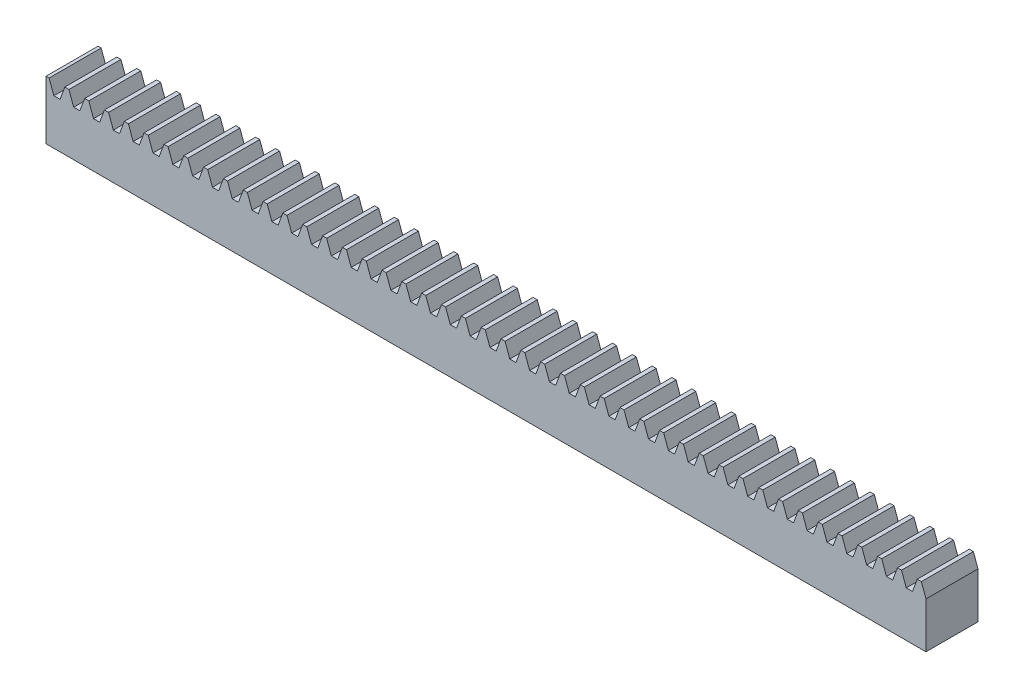
from build123d import *

# Parameters (mm, degrees)
SKETCH1_W           = 67.650000082
SKETCH1_H           = 4
BOSS_EXTRUDE1_DEPTH = 4.5
CUT_EXTRUDE1_DEPTH  = 5


with BuildPart() as part:
    # Sketch1 → Boss-Extrude1 (new body)
    with BuildSketch(Plane(origin=(0, 0, 0), x_dir=(1, 0, 0), z_dir=(0, 1, 0))):
        with Locations((33.825000041, 2)):
            Rectangle(SKETCH1_W, SKETCH1_H)
    extrude(amount=BOSS_EXTRUDE1_DEPTH)

    # Sketch2 → Cut-Extrude1 (cut, through all)
    with BuildSketch(Plane.XY):
        Polygon((0.239013956, 4.5), (0.60298419, 3.5), (0.841998146, 3.5), (1.081012101, 3.5), (1.444982335, 4.5), align=None)
        Polygon((1.763013956, 4.5), (2.12698419, 3.5), (2.365998146, 3.5), (2.605012101, 3.5), (2.968982335, 4.5), align=None)
        Polygon((3.287013956, 4.5), (3.65098419, 3.5), (3.889998146, 3.5), (4.129012101, 3.5), (4.492982335, 4.5), align=None)
        Polygon((4.811013956, 4.5), (5.17498419, 3.5), (5.413998146, 3.5), (5.653012101, 3.5), (6.016982335, 4.5), align=None)
        Polygon((6.335013956, 4.5), (6.69898419, 3.5), (6.937998146, 3.5), (7.177012101, 3.5), (7.540982335, 4.5), align=None)
        Polygon((7.859013956, 4.5), (8.22298419, 3.5), (8.461998146, 3.5), (8.701012101, 3.5), (9.064982335, 4.5), align=None)
        Polygon((9.383013956, 4.5), (9.74698419, 3.5), (9.985998146, 3.5), (10.225012101, 3.5), (10.588982335, 4.5), align=None)
        Polygon((10.907013956, 4.5), (11.27098419, 3.5), (11.509998146, 3.5), (11.749012101, 3.5), (12.112982335, 4.5), align=None)
        Polygon((12.431013956, 4.5), (12.79498419, 3.5), (13.033998146, 3.5), (13.273012101, 3.5), (13.636982335, 4.5), align=None)
        Polygon((13.955013956, 4.5), (14.31898419, 3.5), (14.557998146, 3.5), (14.797012101, 3.5), (15.160982335, 4.5), align=None)
        Polygon((15.479013956, 4.5), (15.84298419, 3.5), (16.081998146, 3.5), (16.321012101, 3.5), (16.684982335, 4.5), align=None)
        Polygon((17.003013956, 4.5), (17.36698419, 3.5), (17.605998146, 3.5), (17.845012101, 3.5), (18.208982335, 4.5), align=None)
        Polygon((18.527013956, 4.5), (18.89098419, 3.5), (19.129998146, 3.5), (19.369012101, 3.5), (19.732982335, 4.5), align=None)
        Polygon((20.051013956, 4.5), (20.41498419, 3.5), (20.653998146, 3.5), (20.893012101, 3.5), (21.256982335, 4.5), align=None)
        Polygon((21.575013956, 4.5), (21.93898419, 3.5), (22.177998146, 3.5), (22.417012101, 3.5), (22.780982335, 4.5), align=None)
        Polygon((23.099013956, 4.5), (23.46298419, 3.5), (23.701998146, 3.5), (23.941012101, 3.5), (24.304982335, 4.5), align=None)
        Polygon((24.623013956, 4.5), (24.98698419, 3.5), (25.225998146, 3.5), (25.465012101, 3.5), (25.828982335, 4.5), align=None)
        Polygon((26.147013956, 4.5), (26.51098419, 3.5), (26.749998146, 3.5), (26.989012101, 3.5), (27.352982335, 4.5), align=None)
        Polygon((27.671013956, 4.5), (28.03498419, 3.5), (28.273998146, 3.5), (28.513012101, 3.5), (28.876982335, 4.5), align=None)
        Polygon((29.195013956, 4.5), (29.55898419, 3.5), (29.797998146, 3.5), (30.037012101, 3.5), (30.400982335, 4.5), align=None)
        Polygon((30.719013956, 4.5), (31.08298419, 3.5), (31.321998146, 3.5), (31.561012101, 3.5), (31.924982335, 4.5), align=None)
        Polygon((32.243013956, 4.5), (32.60698419, 3.5), (32.845998146, 3.5), (33.085012101, 3.5), (33.448982335, 4.5), align=None)
        Polygon((33.767013956, 4.5), (34.13098419, 3.5), (34.369998146, 3.5), (34.609012101, 3.5), (34.972982335, 4.5), align=None)
        Polygon((35.291013956, 4.5), (35.65498419, 3.5), (35.893998146, 3.5), (36.133012101, 3.5), (36.496982335, 4.5), align=None)
        Polygon((36.815013956, 4.5), (37.17898419, 3.5), (37.417998146, 3.5), (37.657012101, 3.5), (38.020982335, 4.5), align=None)
        Polygon((38.339013956, 4.5), (38.70298419, 3.5), (38.941998146, 3.5), (39.181012101, 3.5), (39.544982335, 4.5), align=None)
        Polygon((39.863013956, 4.5), (40.22698419, 3.5), (40.465998146, 3.5), (40.705012101, 3.5), (41.068982335, 4.5), align=None)
        Polygon((41.387013956, 4.5), (41.75098419, 3.5), (41.989998146, 3.5), (42.229012101, 3.5), (42.592982335, 4.5), align=None)
        Polygon((42.911013956, 4.5), (43.27498419, 3.5), (43.513998146, 3.5), (43.753012101, 3.5), (44.116982335, 4.5), align=None)
        Polygon((44.435013956, 4.5), (44.79898419, 3.5), (45.037998146, 3.5), (45.277012101, 3.5), (45.640982335, 4.5), align=None)
        Polygon((45.959013956, 4.5), (46.32298419, 3.5), (46.561998146, 3.5), (46.801012101, 3.5), (47.164982335, 4.5), align=None)
        Polygon((47.483013956, 4.5), (47.84698419, 3.5), (48.085998146, 3.5), (48.325012101, 3.5), (48.688982335, 4.5), align=None)
        Polygon((49.007013956, 4.5), (49.37098419, 3.5), (49.609998146, 3.5), (49.849012101, 3.5), (50.212982335, 4.5), align=None)
        Polygon((50.531013956, 4.5), (50.89498419, 3.5), (51.133998146, 3.5), (51.373012101, 3.5), (51.736982335, 4.5), align=None)
        Polygon((52.055013956, 4.5), (52.41898419, 3.5), (52.657998146, 3.5), (52.897012101, 3.5), (53.260982335, 4.5), align=None)
        Polygon((53.579013956, 4.5), (53.94298419, 3.5), (54.181998146, 3.5), (54.421012101, 3.5), (54.784982335, 4.5), align=None)
        Polygon((55.103013956, 4.5), (55.46698419, 3.5), (55.705998146, 3.5), (55.945012101, 3.5), (56.308982335, 4.5), align=None)
        Polygon((56.627013956, 4.5), (56.99098419, 3.5), (57.229998146, 3.5), (57.469012101, 3.5), (57.832982335, 4.5), align=None)
        Polygon((58.151013956, 4.5), (58.51498419, 3.5), (58.753998146, 3.5), (58.993012101, 3.5), (59.356982335, 4.5), align=None)
        Polygon((59.675013956, 4.5), (60.03898419, 3.5), (60.277998146, 3.5), (60.517012101, 3.5), (60.880982335, 4.5), align=None)
        Polygon((61.199013956, 4.5), (61.56298419, 3.5), (61.801998146, 3.5), (62.041012101, 3.5), (62.404982335, 4.5), align=None)
        Polygon((62.723013956, 4.5), (63.08698419, 3.5), (63.325998146, 3.5), (63.565012101, 3.5), (63.928982335, 4.5), align=None)
        Polygon((64.247013956, 4.5), (64.61098419, 3.5), (64.849998146, 3.5), (65.089012101, 3.5), (65.452982335, 4.5), align=None)
        Polygon((65.771013956, 4.5), (66.13498419, 3.5), (66.373998146, 3.5), (66.613012101, 3.5), (66.976982335, 4.5), align=None)
        Polygon((67.295013956, 4.5), (67.65898419, 3.5), (67.897998146, 3.5), (68.137012101, 3.5), (68.500982335, 4.5), align=None)
        Polygon((68.819013956, 4.5), (69.18298419, 3.5), (69.421998146, 3.5), (69.661012101, 3.5), (70.024982335, 4.5), align=None)
        Polygon((70.343013956, 4.5), (70.70698419, 3.5), (70.945998146, 3.5), (71.185012101, 3.5), (71.548982335, 4.5), align=None)
        Polygon((71.867013956, 4.5), (72.23098419, 3.5), (72.469998146, 3.5), (72.709012101, 3.5), (73.072982335, 4.5), align=None)
        Polygon((73.391013956, 4.5), (73.75498419, 3.5), (73.993998146, 3.5), (74.233012101, 3.5), (74.596982335, 4.5), align=None)
        Polygon((74.915013956, 4.5), (75.27898419, 3.5), (75.517998146, 3.5), (75.757012101, 3.5), (76.120982335, 4.5), align=None)
        Polygon((76.439013956, 4.5), (76.80298419, 3.5), (77.041998146, 3.5), (77.281012101, 3.5), (77.644982335, 4.5), align=None)
        Polygon((77.963013956, 4.5), (78.32698419, 3.5), (78.565998146, 3.5), (78.805012101, 3.5), (79.168982335, 4.5), align=None)
        Polygon((79.487013956, 4.5), (79.85098419, 3.5), (80.089998146, 3.5), (80.329012101, 3.5), (80.692982335, 4.5), align=None)
        Polygon((81.011013956, 4.5), (81.37498419, 3.5), (81.613998146, 3.5), (81.853012101, 3.5), (82.216982335, 4.5), align=None)
        Polygon((82.535013956, 4.5), (82.89898419, 3.5), (83.137998146, 3.5), (83.377012101, 3.5), (83.740982335, 4.5), align=None)
        Polygon((84.059013956, 4.5), (84.42298419, 3.5), (84.661998146, 3.5), (84.901012101, 3.5), (85.264982335, 4.5), align=None)
        Polygon((85.583013956, 4.5), (85.94698419, 3.5), (86.185998146, 3.5), (86.425012101, 3.5), (86.788982335, 4.5), align=None)
        Polygon((87.107013956, 4.5), (87.47098419, 3.5), (87.709998146, 3.5), (87.949012101, 3.5), (88.312982335, 4.5), align=None)
        Polygon((88.631013956, 4.5), (88.99498419, 3.5), (89.233998146, 3.5), (89.473012101, 3.5), (89.836982335, 4.5), align=None)
        Polygon((90.155013956, 4.5), (90.51898419, 3.5), (90.757998146, 3.5), (90.997012101, 3.5), (91.360982335, 4.5), align=None)
        Polygon((91.679013956, 4.5), (92.04298419, 3.5), (92.281998146, 3.5), (92.521012101, 3.5), (92.884982335, 4.5), align=None)
        Polygon((93.203013956, 4.5), (93.56698419, 3.5), (93.805998146, 3.5), (94.045012101, 3.5), (94.408982335, 4.5), align=None)
        Polygon((94.727013956, 4.5), (95.09098419, 3.5), (95.329998146, 3.5), (95.569012101, 3.5), (95.932982335, 4.5), align=None)
        Polygon((96.251013956, 4.5), (96.61498419, 3.5), (96.853998146, 3.5), (97.093012101, 3.5), (97.456982335, 4.5), align=None)
        Polygon((97.775013956, 4.5), (98.13898419, 3.5), (98.377998146, 3.5), (98.617012101, 3.5), (98.980982335, 4.5), align=None)
        Polygon((99.299013956, 4.5), (99.66298419, 3.5), (99.901998146, 3.5), (100.141012101, 3.5), (100.504982335, 4.5), align=None)
        Polygon((100.823013956, 4.5), (101.18698419, 3.5), (101.425998146, 3.5), (101.665012101, 3.5), (102.028982335, 4.5), align=None)
        Polygon((102.347013956, 4.5), (102.71098419, 3.5), (102.949998146, 3.5), (103.189012101, 3.5), (103.552982335, 4.5), align=None)
        Polygon((103.871013956, 4.5), (104.23498419, 3.5), (104.473998146, 3.5), (104.713012101, 3.5), (105.076982335, 4.5), align=None)
        Polygon((105.395013956, 4.5), (105.75898419, 3.5), (105.997998146, 3.5), (106.237012101, 3.5), (106.600982335, 4.5), align=None)
        Polygon((106.919013956, 4.5), (107.28298419, 3.5), (107.521998146, 3.5), (107.761012101, 3.5), (108.124982335, 4.5), align=None)
        Polygon((108.443013956, 4.5), (108.80698419, 3.5), (109.045998146, 3.5), (109.285012101, 3.5), (109.648982335, 4.5), align=None)
        Polygon((109.967013956, 4.5), (110.33098419, 3.5), (110.569998146, 3.5), (110.809012101, 3.5), (111.172982335, 4.5), align=None)
        Polygon((111.491013956, 4.5), (111.85498419, 3.5), (112.093998146, 3.5), (112.333012101, 3.5), (112.696982335, 4.5), align=None)
        Polygon((113.015013956, 4.5), (113.37898419, 3.5), (113.617998146, 3.5), (113.857012101, 3.5), (114.220982335, 4.5), align=None)
        Polygon((114.539013956, 4.5), (114.90298419, 3.5), (115.141998146, 3.5), (115.381012101, 3.5), (115.744982335, 4.5), align=None)
        Polygon((116.063013956, 4.5), (116.42698419, 3.5), (116.665998146, 3.5), (116.905012101, 3.5), (117.268982335, 4.5), align=None)
        Polygon((117.587013956, 4.5), (117.95098419, 3.5), (118.189998146, 3.5), (118.429012101, 3.5), (118.792982335, 4.5), align=None)
        Polygon((119.111013956, 4.5), (119.47498419, 3.5), (119.713998146, 3.5), (119.953012101, 3.5), (120.316982335, 4.5), align=None)
        Polygon((120.635013956, 4.5), (120.99898419, 3.5), (121.237998146, 3.5), (121.477012101, 3.5), (121.840982335, 4.5), align=None)
        Polygon((122.159013956, 4.5), (122.52298419, 3.5), (122.761998146, 3.5), (123.001012101, 3.5), (123.364982335, 4.5), align=None)
        Polygon((123.683013956, 4.5), (124.04698419, 3.5), (124.285998146, 3.5), (124.525012101, 3.5), (124.888982335, 4.5), align=None)
        Polygon((125.207013956, 4.5), (125.57098419, 3.5), (125.809998146, 3.5), (126.049012101, 3.5), (126.412982335, 4.5), align=None)
        Polygon((126.731013956, 4.5), (127.09498419, 3.5), (127.333998146, 3.5), (127.573012101, 3.5), (127.936982335, 4.5), align=None)
        Polygon((128.255013956, 4.5), (128.61898419, 3.5), (128.857998146, 3.5), (129.097012101, 3.5), (129.460982335, 4.5), align=None)
        Polygon((129.779013956, 4.5), (130.14298419, 3.5), (130.381998146, 3.5), (130.621012101, 3.5), (130.984982335, 4.5), align=None)
        Polygon((131.303013956, 4.5), (131.66698419, 3.5), (131.905998146, 3.5), (132.145012101, 3.5), (132.508982335, 4.5), align=None)
        Polygon((132.827013956, 4.5), (133.19098419, 3.5), (133.429998146, 3.5), (133.669012101, 3.5), (134.032982335, 4.5), align=None)
        Polygon((134.351013956, 4.5), (134.71498419, 3.5), (134.953998146, 3.5), (135.193012101, 3.5), (135.556982335, 4.5), align=None)
        Polygon((135.875013956, 4.5), (136.23898419, 3.5), (136.477998146, 3.5), (136.717012101, 3.5), (137.080982335, 4.5), align=None)
        Polygon((137.399013956, 4.5), (137.76298419, 3.5), (138.001998146, 3.5), (138.241012101, 3.5), (138.604982335, 4.5), align=None)
        Polygon((138.923013956, 4.5), (139.28698419, 3.5), (139.525998146, 3.5), (139.765012101, 3.5), (140.128982335, 4.5), align=None)
        Polygon((140.447013956, 4.5), (140.81098419, 3.5), (141.049998146, 3.5), (141.289012101, 3.5), (141.652982335, 4.5), align=None)
        Polygon((141.971013956, 4.5), (142.33498419, 3.5), (142.573998146, 3.5), (142.813012101, 3.5), (143.176982335, 4.5), align=None)
        Polygon((143.495013956, 4.5), (143.85898419, 3.5), (144.097998146, 3.5), (144.337012101, 3.5), (144.700982335, 4.5), align=None)
        Polygon((145.019013956, 4.5), (145.38298419, 3.5), (145.621998146, 3.5), (145.861012101, 3.5), (146.224982335, 4.5), align=None)
        Polygon((146.543013956, 4.5), (146.90698419, 3.5), (147.145998146, 3.5), (147.385012101, 3.5), (147.748982335, 4.5), align=None)
        Polygon((148.067013956, 4.5), (148.43098419, 3.5), (148.669998146, 3.5), (148.909012101, 3.5), (149.272982335, 4.5), align=None)
        Polygon((149.591013956, 4.5), (149.95498419, 3.5), (150.193998146, 3.5), (150.433012101, 3.5), (150.796982335, 4.5), align=None)
        Polygon((151.115013956, 4.5), (151.47898419, 3.5), (151.717998146, 3.5), (151.957012101, 3.5), (152.320982335, 4.5), align=None)
        Polygon((152.639013956, 4.5), (153.00298419, 3.5), (153.241998146, 3.5), (153.481012101, 3.5), (153.844982335, 4.5), align=None)
        Polygon((154.163013956, 4.5), (154.52698419, 3.5), (154.765998146, 3.5), (155.005012101, 3.5), (155.368982335, 4.5), align=None)
        Polygon((155.687013956, 4.5), (156.05098419, 3.5), (156.289998146, 3.5), (156.529012101, 3.5), (156.892982335, 4.5), align=None)
        Polygon((157.211013956, 4.5), (157.57498419, 3.5), (157.813998146, 3.5), (158.053012101, 3.5), (158.416982335, 4.5), align=None)
        Polygon((158.735013956, 4.5), (159.09898419, 3.5), (159.337998146, 3.5), (159.577012101, 3.5), (159.940982335, 4.5), align=None)
        Polygon((160.259013956, 4.5), (160.62298419, 3.5), (160.861998146, 3.5), (161.101012101, 3.5), (161.464982335, 4.5), align=None)
        Polygon((161.783013956, 4.5), (162.14698419, 3.5), (162.385998146, 3.5), (162.625012101, 3.5), (162.988982335, 4.5), align=None)
        Polygon((163.307013956, 4.5), (163.67098419, 3.5), (163.909998146, 3.5), (164.149012101, 3.5), (164.512982335, 4.5), align=None)
        Polygon((164.831013956, 4.5), (165.19498419, 3.5), (165.433998146, 3.5), (165.673012101, 3.5), (166.036982335, 4.5), align=None)
        Polygon((166.355013956, 4.5), (166.71898419, 3.5), (166.957998146, 3.5), (167.197012101, 3.5), (167.560982335, 4.5), align=None)
        Polygon((167.879013956, 4.5), (168.24298419, 3.5), (168.481998146, 3.5), (168.721012101, 3.5), (169.084982335, 4.5), align=None)
        Polygon((169.403013956, 4.5), (169.76698419, 3.5), (170.005998146, 3.5), (170.245012101, 3.5), (170.608982335, 4.5), align=None)
        Polygon((170.927013956, 4.5), (171.29098419, 3.5), (171.529998146, 3.5), (171.769012101, 3.5), (172.132982335, 4.5), align=None)
        Polygon((172.451013956, 4.5), (172.81498419, 3.5), (173.053998146, 3.5), (173.293012101, 3.5), (173.656982335, 4.5), align=None)
        Polygon((173.975013956, 4.5), (174.33898419, 3.5), (174.577998146, 3.5), (174.817012101, 3.5), (175.180982335, 4.5), align=None)
        Polygon((175.499013956, 4.5), (175.86298419, 3.5), (176.101998146, 3.5), (176.341012101, 3.5), (176.704982335, 4.5), align=None)
        Polygon((177.023013956, 4.5), (177.38698419, 3.5), (177.625998146, 3.5), (177.865012101, 3.5), (178.228982335, 4.5), align=None)
        Polygon((178.547013956, 4.5), (178.91098419, 3.5), (179.149998146, 3.5), (179.389012101, 3.5), (179.752982335, 4.5), align=None)
        Polygon((180.071013956, 4.5), (180.43498419, 3.5), (180.673998146, 3.5), (180.913012101, 3.5), (181.276982335, 4.5), align=None)
        Polygon((181.595013956, 4.5), (181.95898419, 3.5), (182.197998146, 3.5), (182.437012101, 3.5), (182.800982335, 4.5), align=None)
        Polygon((183.119013956, 4.5), (183.48298419, 3.5), (183.721998146, 3.5), (183.961012101, 3.5), (184.324982335, 4.5), align=None)
        Polygon((184.643013956, 4.5), (185.00698419, 3.5), (185.245998146, 3.5), (185.485012101, 3.5), (185.848982335, 4.5), align=None)
        Polygon((186.167013956, 4.5), (186.53098419, 3.5), (186.769998146, 3.5), (187.009012101, 3.5), (187.372982335, 4.5), align=None)
        Polygon((187.691013956, 4.5), (188.05498419, 3.5), (188.293998146, 3.5), (188.533012101, 3.5), (188.896982335, 4.5), align=None)
        Polygon((189.215013956, 4.5), (189.57898419, 3.5), (189.817998146, 3.5), (190.057012101, 3.5), (190.420982335, 4.5), align=None)
    extrude(amount=-CUT_EXTRUDE1_DEPTH, mode=Mode.SUBTRACT)


solid = part.part
